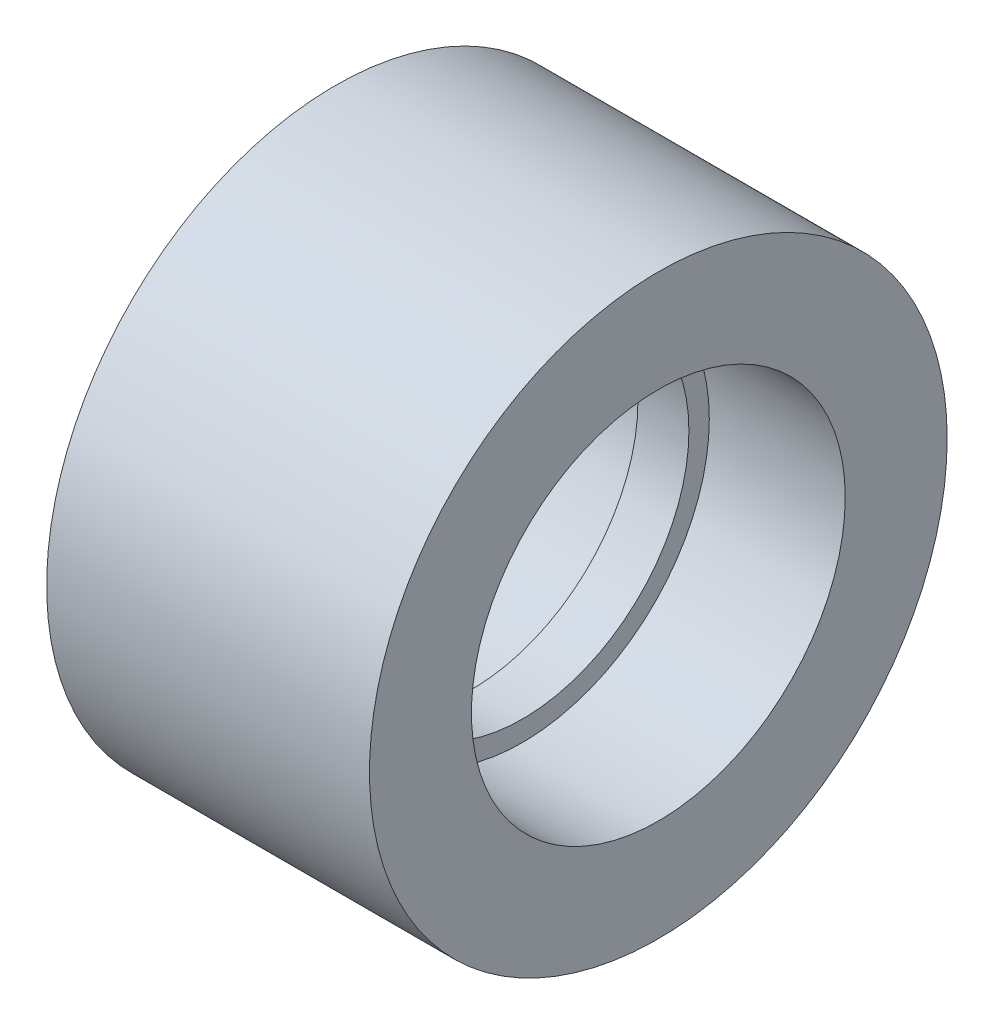
from build123d import *


with BuildPart() as part:
    # Sketch2 → Revolve1 (revolve)
    with BuildSketch(Plane(origin=(0, 0, 0), x_dir=(1, 0, 0), z_dir=(0, 1, 0))):
        Polygon((-9.5, 17), (9.5, 17), (9.5, 11), (1.5, 11), (1.5, 9.8), (-1.5, 9.8), (-1.5, 11), (-9.5, 11), align=None)
    revolve(axis=Axis((88.99, 0, 0), (-1, 0, 0)))


solid = part.part
